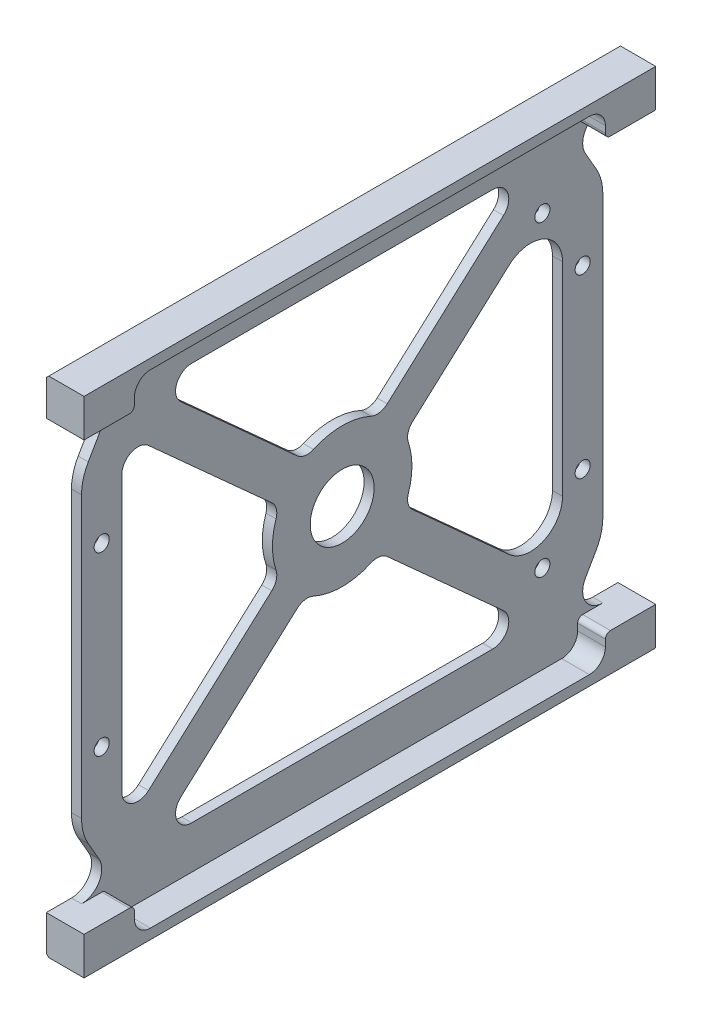
from build123d import *

# Parameters (mm, degrees)
BOSS_EXTRUDE1_DEPTH = 56.75
SKETCH2_W           = 5
SKETCH2_H           = 85
SKETCH2_R           = 1.5
CUT_EXTRUDE1_DEPTH  = 2
SKETCH3_R           = 6.35
SKETCH3_R_2         = 1.5
CUT_EXTRUDE2_DEPTH  = 3
CHAMFER1_SIZE       = 0.5
CUT_EXTRUDE3_DEPTH  = 5.5
CUT_EXTRUDE4_DEPTH  = 10


with BuildPart() as part:
    # Sketch1 → Boss-Extrude1 (new body, symmetric)
    with BuildSketch(Plane.XY):
        Polygon((0, 50), (0, -50), (7.5, -50), (7.5, -42.5), (2, -42.5), (2, 42.5), (7.5, 42.5), (7.5, 50), align=None)
    extrude(amount=BOSS_EXTRUDE1_DEPTH, both=True)

    # Sketch2 → Cut-Extrude1 (cut)
    with BuildSketch(Plane(origin=(2, 0, 0), x_dir=(0, 0, -1), z_dir=(1, 0, 0))):
        with Locations((-54.25, 0)):
            Rectangle(SKETCH2_W, SKETCH2_H)
        with Locations((54.25, 0)):
            Rectangle(SKETCH2_W, SKETCH2_H)
        with Locations((-47.75, 17.5)):
            Circle(SKETCH2_R)
        with Locations((-47.75, -17.5)):
            Circle(SKETCH2_R)
        with Locations((47.75, 17.5)):
            Circle(SKETCH2_R)
        with Locations((47.75, -17.5)):
            Circle(SKETCH2_R)
    extrude(amount=-CUT_EXTRUDE1_DEPTH, mode=Mode.SUBTRACT)

    # Sketch3 → Cut-Extrude2 (cut, through all)
    with BuildSketch(Plane(origin=(2, 0, 0), x_dir=(0, 0, -1), z_dir=(1, 0, 0))):
        Circle(SKETCH3_R)
        with Locations((39.75, 30.5)):
            Circle(SKETCH3_R_2)
        with Locations((39.75, -30.5)):
            Circle(SKETCH3_R_2)
        with BuildLine():
            Line((-29.899655804, -39.5), (29.899655804, -39.5))
            ThreePointArc((29.899655804, -39.5), (32.863003185, -37.464823364), (32.027336169, -33.968392001))
            Line((32.027336169, -33.968392001), (8.946350194, -13.129558949))
            ThreePointArc((8.946350194, -13.129558949), (7.399307524, -12.392275536), (5.701057458, -12.622220243))
            ThreePointArc((5.701057458, -12.622220243), (0, -13.85), (-5.701057458, -12.622220243))
            ThreePointArc((-5.701057458, -12.622220243), (-7.399307524, -12.392275536), (-8.946350194, -13.129558949))
            Line((-8.946350194, -13.129558949), (-32.027336169, -33.968392001))
            ThreePointArc((-32.027336169, -33.968392001), (-32.863003185, -37.464823364), (-29.899655804, -39.5))
        make_face()
        with BuildLine():
            Line((-43.75, -27.303546383), (-43.75, 27.303546383))
            ThreePointArc((-43.75, 27.303546383), (-41.864426198, 30.204926241), (-38.447319635, 29.660154382))
            Line((-38.447319635, 29.660154382), (-13.972366805, 7.562768399))
            ThreePointArc((-13.972366805, 7.562768399), (-13.081370721, 6.098851109), (-13.137175803, 4.386013216))
            ThreePointArc((-13.137175803, 4.386013216), (-13.85, 0), (-13.137175803, -4.386013216))
            ThreePointArc((-13.137175803, -4.386013216), (-13.081370721, -6.098851109), (-13.972366805, -7.562768399))
            Line((-13.972366805, -7.562768399), (-38.447319635, -29.660154382))
            ThreePointArc((-38.447319635, -29.660154382), (-41.864426198, -30.204926241), (-43.75, -27.303546383))
        make_face()
        with BuildLine():
            Line((-29.899655804, 39.5), (29.899655804, 39.5))
            ThreePointArc((29.899655804, 39.5), (32.863003185, 37.464823364), (32.027336169, 33.968392001))
            Line((32.027336169, 33.968392001), (8.946350194, 13.129558949))
            ThreePointArc((8.946350194, 13.129558949), (7.399307524, 12.392275536), (5.701057458, 12.622220243))
            ThreePointArc((5.701057458, 12.622220243), (0, 13.85), (-5.701057458, 12.622220243))
            ThreePointArc((-5.701057458, 12.622220243), (-7.399307524, 12.392275536), (-8.946350194, 13.129558949))
            Line((-8.946350194, 13.129558949), (-32.027336169, 33.968392001))
            ThreePointArc((-32.027336169, 33.968392001), (-32.863003185, 37.464823364), (-29.899655804, 39.5))
        make_face()
        with BuildLine():
            Line((43.75, -20.159375539), (43.75, 20.159375539))
            ThreePointArc((43.75, 20.159375539), (39.978852396, 25.962135255), (33.144639269, 24.872591538))
            Line((33.144639269, 24.872591538), (13.972366805, 7.562768399))
            ThreePointArc((13.972366805, 7.562768399), (13.081370721, 6.098851109), (13.137175803, 4.386013216))
            ThreePointArc((13.137175803, 4.386013216), (13.85, 0), (13.137175803, -4.386013216))
            ThreePointArc((13.137175803, -4.386013216), (13.081370721, -6.098851109), (13.972366805, -7.562768399))
            Line((13.972366805, -7.562768399), (33.144639269, -24.872591538))
            ThreePointArc((33.144639269, -24.872591538), (39.978852396, -25.962135255), (43.75, -20.159375539))
        make_face()
    extrude(amount=-CUT_EXTRUDE2_DEPTH, mode=Mode.SUBTRACT)

    # Chamfer1
    chamfer1_edges = [part.edges().sort_by_distance(p)[0] for p in [
        (0, -50, 0),
        (0, 50, 0),
    ]]
    chamfer(chamfer1_edges, length=CHAMFER1_SIZE)

    # Sketch4 → Cut-Extrude3 (cut)
    with BuildSketch(Plane(origin=(7.5, 0, 0), x_dir=(0, 0, -1), z_dir=(1, 0, 0))):
        with BuildLine():
            Line((43.575, -48), (-43.575, -48))
            ThreePointArc((-43.575, -48), (-45.82006403, -47.07006403), (-46.75, -44.825))
            Line((-46.75, -44.825), (-46.75, -43.5))
            ThreePointArc((-46.75, -43.5), (-47.042893219, -42.792893219), (-47.75, -42.5))
            Line((-47.75, -42.5), (47.75, -42.5))
            ThreePointArc((47.75, -42.5), (47.042893219, -42.792893219), (46.75, -43.5))
            Line((46.75, -43.5), (46.75, -44.825))
            ThreePointArc((46.75, -44.825), (45.82006403, -47.07006403), (43.575, -48))
        make_face()
        with BuildLine():
            Line((-46.75, 44.825), (-46.75, 43.5))
            ThreePointArc((-46.75, 43.5), (-47.042893219, 42.792893219), (-47.75, 42.5))
            Line((-47.75, 42.5), (47.75, 42.5))
            ThreePointArc((47.75, 42.5), (47.042893219, 42.792893219), (46.75, 43.5))
            Line((46.75, 43.5), (46.75, 44.825))
            ThreePointArc((46.75, 44.825), (45.82006403, 47.07006403), (43.575, 48))
            Line((43.575, 48), (-43.575, 48))
            ThreePointArc((-43.575, 48), (-45.82006403, 47.07006403), (-46.75, 44.825))
        make_face()
    extrude(amount=-CUT_EXTRUDE3_DEPTH, mode=Mode.SUBTRACT)

    # Sketch5 → Cut-Extrude4 (cut)
    with BuildSketch(Plane.ZY):
        with BuildLine():
            ThreePointArc((-51.75, 27.820508076), (-51.409258263, 30.408698527), (-50.410254038, 32.820508076))
            Line((-50.410254038, 32.820508076), (-48.285898385, 36.5))
            ThreePointArc((-48.285898385, 36.5), (-48.285898385, 40.5), (-51.75, 42.5))
            Line((-51.75, 42.5), (-51.75, 27.820508076))
        make_face()
        with BuildLine():
            ThreePointArc((-50.410254038, -32.820508076), (-51.409258263, -30.408698527), (-51.75, -27.820508076))
            Line((-51.75, -27.820508076), (-51.75, -42.5))
            ThreePointArc((-51.75, -42.5), (-48.285898385, -40.5), (-48.285898385, -36.5))
            Line((-48.285898385, -36.5), (-50.410254038, -32.820508076))
        make_face()
    cut_extrude4 = extrude(amount=-CUT_EXTRUDE4_DEPTH, mode=Mode.SUBTRACT)

    # Mirror1: Cut-Extrude4 across plane
    add(cut_extrude4.mirror(Plane.XY), mode=Mode.SUBTRACT)


solid = part.part
